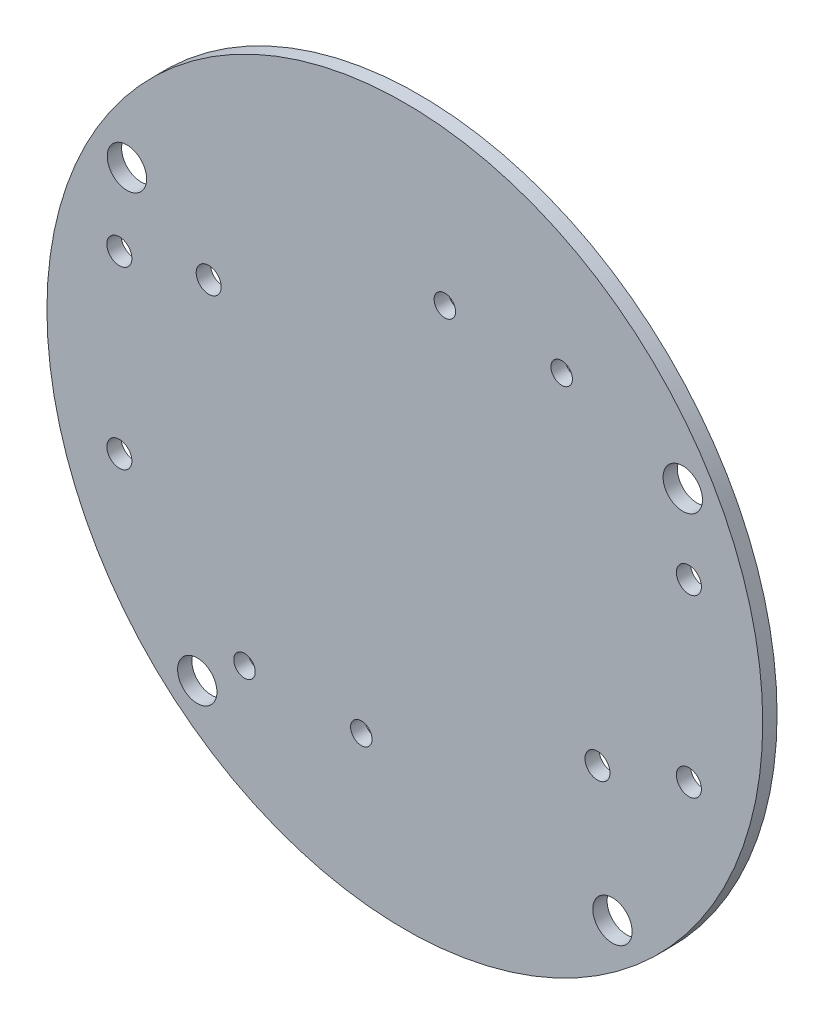
from build123d import *

# Parameters (mm, degrees)
ESBO_O1_R                = 50
RESSALTO_EXTRUS_O1_DEPTH = 2
ESBO_O2_R                = 2.75
CORTE_EXTRUS_O1_DEPTH    = 2
ESBO_O3_R                = 1.75
ESBO_O3_R_2              = 1.5
CORTE_EXTRUS_O2_DEPTH    = 10


with BuildPart() as part:
    # Esboço1 → Ressalto-extrusão1 (new body)
    with BuildSketch(Plane.XY):
        Circle(ESBO_O1_R)
    extrude(amount=RESSALTO_EXTRUS_O1_DEPTH)

    # Esboço2 → Corte-extrusão1 (cut)
    with BuildSketch(Plane.XY.offset(2)):
        with Locations((-29, -34.409301068)):
            Circle(ESBO_O2_R)
        with Locations((29, -34.409301068)):
            Circle(ESBO_O2_R)
        with Locations((-38.824197531, 22.752619324)):
            Circle(ESBO_O2_R)
        with Locations((38.824197531, 22.752619324)):
            Circle(ESBO_O2_R)
    extrude(amount=-CORTE_EXTRUS_O1_DEPTH, mode=Mode.SUBTRACT)

    # Esboço3 → Corte-extrusão2 (cut)
    with BuildSketch(Plane.XY.offset(2)):
        with Locations((-27.4, 14.89)):
            Circle(ESBO_O3_R)
        with Locations((26.91, -16.73)):
            Circle(ESBO_O3_R)
        with Locations((-39.88, -12.4)):
            Circle(ESBO_O3_R)
        with Locations((-39.88, 12.11)):
            Circle(ESBO_O3_R)
        with Locations((39.68, 12.16)):
            Circle(ESBO_O3_R)
        with Locations((39.68, -12.34)):
            Circle(ESBO_O3_R)
        with Locations((5.59, 28.28)):
            Circle(ESBO_O3_R_2)
        with Locations((21.91, 28.28)):
            Circle(ESBO_O3_R_2)
        with Locations((-6.08, -29.3)):
            Circle(ESBO_O3_R_2)
        with Locations((-22.4, -29.3)):
            Circle(ESBO_O3_R_2)
    extrude(amount=-CORTE_EXTRUS_O2_DEPTH, mode=Mode.SUBTRACT)


solid = part.part
